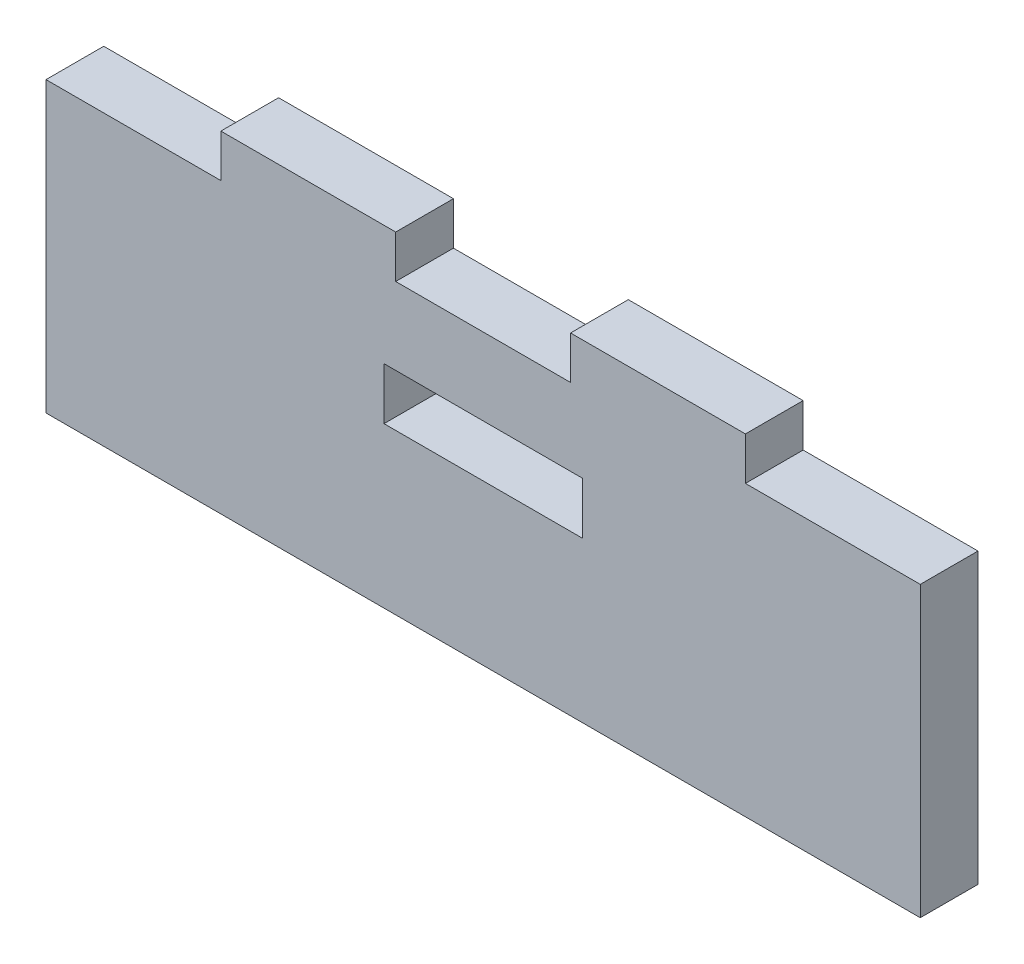
from build123d import *

# Parameters (mm, degrees)
CROQUIS1_W              = 10.3
CROQUIS1_H              = 2.7
SALIENTE_EXTRUIR1_DEPTH = 3


with BuildPart() as part:
    # Croquis1 → Saliente-Extruir1 (new body)
    with BuildSketch(Plane.XY):
        Polygon((10.793788029, 10.735724485), (19.877788029, 10.735724485), (19.877788029, -4.264275515), (-25.542211971, -4.264275515), (-25.542211971, 10.735724485), (-16.458211971, 10.735724485), (-16.458211971, 12.962055963), (-7.374211971, 12.962055963), (-7.374211971, 10.735724485), (1.709788029, 10.735724485), (1.709788029, 12.962055963), (10.793788029, 12.962055963), align=None)
        with Locations((-2.832211971, 5.385724485)):
            Rectangle(CROQUIS1_W, CROQUIS1_H, mode=Mode.SUBTRACT)
    extrude(amount=SALIENTE_EXTRUIR1_DEPTH)


solid = part.part
